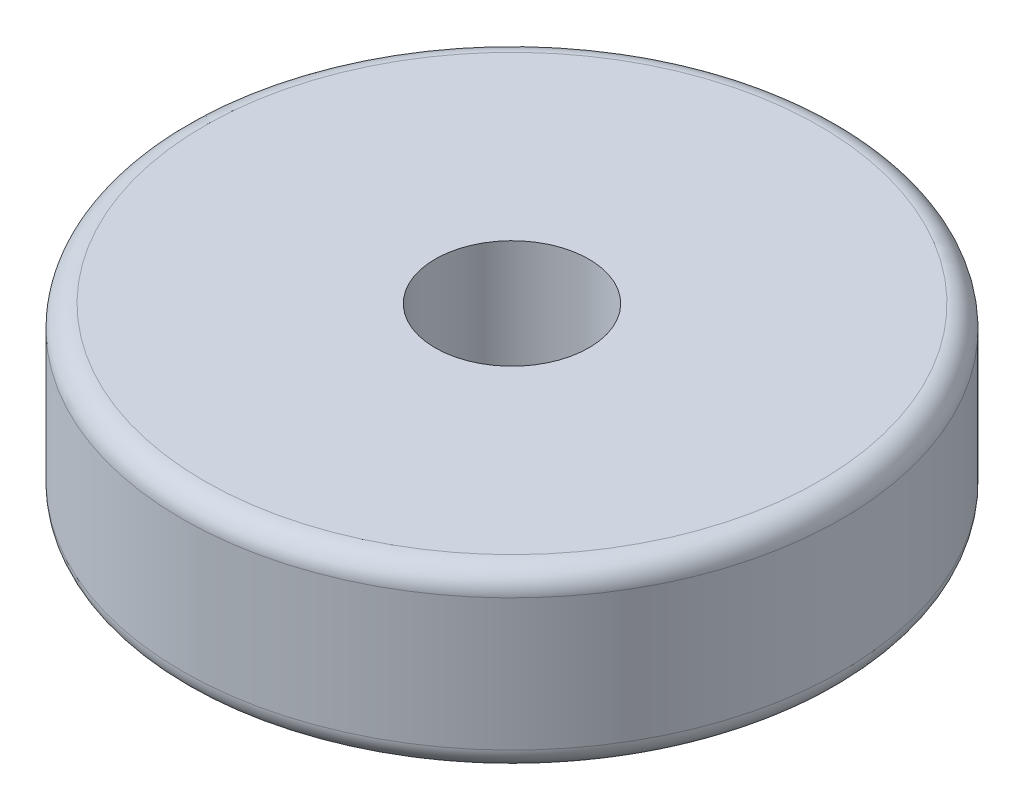
from build123d import *

# Parameters (mm, degrees)
SKETCH1_R           = 7.5
BOSS_EXTRUDE1_DEPTH = 4
SKETCH2_R           = 1.75
CUT_EXTRUDE1_DEPTH  = 4
FILLET1_R           = 0.5


with BuildPart() as part:
    # Sketch1 → Boss-Extrude1 (new body)
    with BuildSketch(Plane(origin=(0, 0, 0), x_dir=(1, 0, 0), z_dir=(0, 1, 0))):
        Circle(SKETCH1_R)
    extrude(amount=BOSS_EXTRUDE1_DEPTH)

    # Sketch2 → Cut-Extrude1 (cut)
    with BuildSketch(Plane(origin=(0, 4, 0), x_dir=(1, 0, 0), z_dir=(0, 1, 0))):
        Circle(SKETCH2_R)
    extrude(amount=-CUT_EXTRUDE1_DEPTH, mode=Mode.SUBTRACT)

    # Fillet1
    fillet1_edges = [part.edges().sort_by_distance(p)[0] for p in [
        (-7.5, 0, 0),
        (-7.5, 4, 0),
    ]]
    fillet(fillet1_edges, radius=FILLET1_R)


solid = part.part
